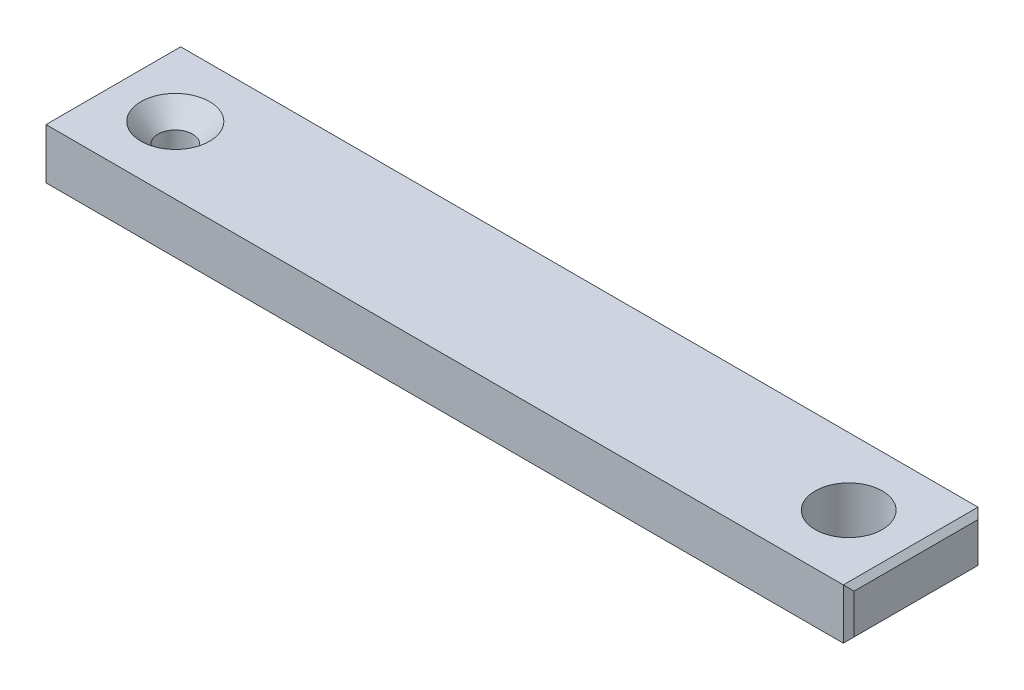
from build123d import *

# Parameters (mm, degrees)
SKETCH1_W                                         = 76.2
SKETCH1_H                                         = 12.7
BOSS_EXTRUDE2_DEPTH                               = 4.7625
CSK_FOR_4_FLAT_HEAD_SOCKET_CAP_SCREW1_D           = 3.2639
CSK_FOR_4_FLAT_HEAD_SOCKET_CAP_SCREW1_CSINK_D     = 6.477
CSK_FOR_4_FLAT_HEAD_SOCKET_CAP_SCREW1_CSINK_ANGLE = 82
CUT_EXTRUDE1_DEPTH                                = 5.7625
CHAMFER1_SIZE                                     = 0.508


with BuildPart() as part:
    # Sketch1 → Boss-Extrude2 (new body)
    with BuildSketch(Plane(origin=(0, 0, 0), x_dir=(1, 0, 0), z_dir=(0, 1, 0))):
        with Locations((-31.75, 0)):
            Rectangle(SKETCH1_W, SKETCH1_H)
    extrude(amount=BOSS_EXTRUDE2_DEPTH)

    # CSK for #4 Flat Head Socket Cap Screw1 (through all)
    with Locations(Plane(origin=(0, 4.7625, 0), x_dir=(1, 0, 0), z_dir=(0, 1, 0))):
        with Locations((-63.5, 0)):
            CounterSinkHole(CSK_FOR_4_FLAT_HEAD_SOCKET_CAP_SCREW1_D / 2, CSK_FOR_4_FLAT_HEAD_SOCKET_CAP_SCREW1_CSINK_D / 2, counter_sink_angle=CSK_FOR_4_FLAT_HEAD_SOCKET_CAP_SCREW1_CSINK_ANGLE)

    # Sketch2 → Cut-Extrude1 (cut, through all)
    with BuildSketch(Plane(origin=(0, 4.7625, 0), x_dir=(1, 0, 0), z_dir=(0, 1, 0))):
        with BuildLine():
            ThreePointArc((3.1623, 0), (2.236083774, 2.236083774), (0, 3.1623))
            Line((0, 3.1623), (0, -3.1623))
            ThreePointArc((0, -3.1623), (2.236083774, -2.236083774), (3.1623, 0))
        make_face()
        with BuildLine():
            Line((0, -3.1623), (0, 3.1623))
            ThreePointArc((0, 3.1623), (-3.1623, 0), (0, -3.1623))
        make_face()
    extrude(amount=-CUT_EXTRUDE1_DEPTH, mode=Mode.SUBTRACT)

    # Chamfer1
    chamfer1_edges = [part.edges().sort_by_distance(p)[0] for p in [
        (-69.85, 2.38125, 6.35),
        (-69.85, 2.38125, -6.35),
        (6.35, 2.38125, -6.35),
        (6.35, 2.38125, 6.35),
        (6.35, 4.7625, 0),
        (-69.85, 4.7625, 0),
        (-69.85, 0, 0),
        (6.35, 0, 0),
    ]]
    chamfer(chamfer1_edges, length=CHAMFER1_SIZE)


solid = part.part
